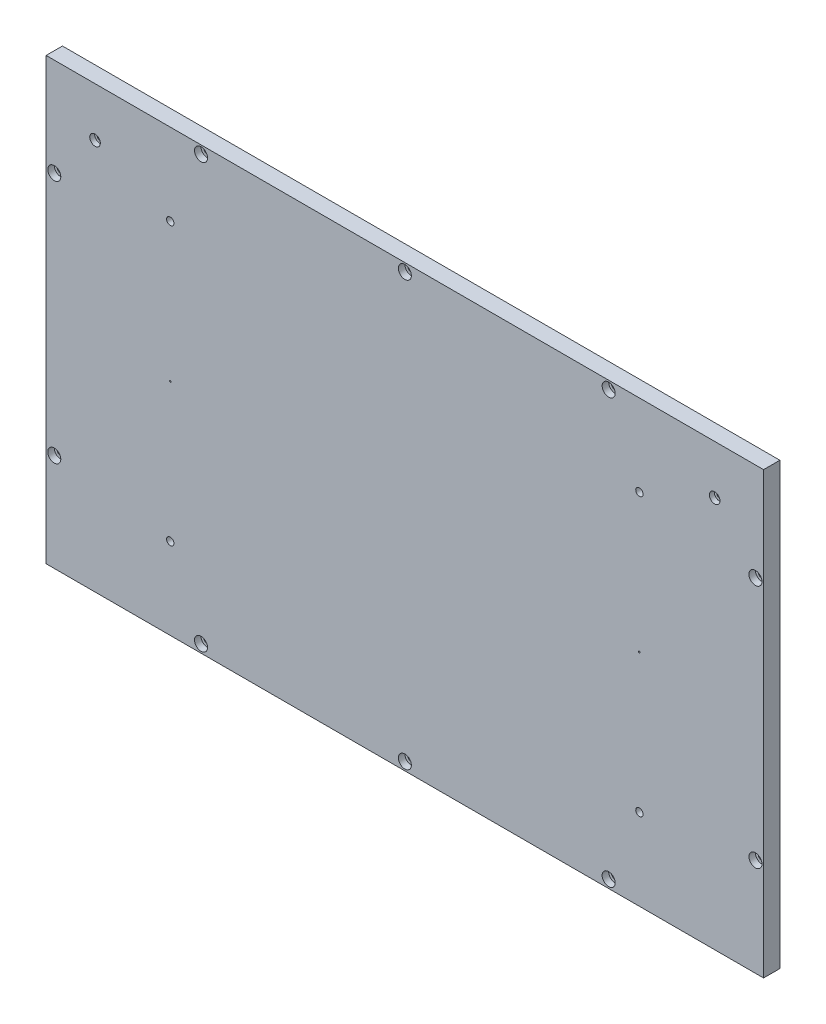
from build123d import *

# Parameters (mm, degrees)
SKETCH1_W                      = 440
SKETCH1_H                      = 270
BOSS_EXTRUDE1_DEPTH            = 10
CBORE_FOR_M4_SHCS4_D           = 4.5
CBORE_FOR_M4_SHCS4_DEPTH       = 11.5
CBORE_FOR_M4_SHCS4_CBORE_D     = 8
CBORE_FOR_M4_SHCS4_CBORE_DEPTH = 4
CBORE_FOR_M4_SHCS4_TIP         = 1.351936393
CBORE_FOR_M3_SHCS1_D           = 3.4
CBORE_FOR_M3_SHCS1_CBORE_D     = 6.5
CBORE_FOR_M3_SHCS1_CBORE_DEPTH = 3


with BuildPart() as part:
    # Sketch1 → Boss-Extrude1 (new body)
    with BuildSketch(Plane.XY):
        with Locations((190, 105)):
            Rectangle(SKETCH1_W, SKETCH1_H)
    extrude(amount=-BOSS_EXTRUDE1_DEPTH)

    # Sketch7 → CBORE for M4 SHCS3 (revolve, cut)
    with BuildSketch(Plane(origin=(46.15, 20, -10), x_dir=(0, 1, 0), z_dir=(1, 0, 0))):
        Polygon((0, 0), (0, 12.851936393), (2.25, 11.5), (2.25, 4), (4, 4), (4, 0), align=None)
    cbore_for_m4_shcs3 = revolve(axis=Axis((46.15, 20, -16.35), (0, 0, 1)), mode=Mode.SUBTRACT)

    # Mirror1: CBORE for M4 SHCS3 across plane
    add(cbore_for_m4_shcs3.mirror(Plane(origin=(0, 105, 0), x_dir=(0, 0, 1), z_dir=(0, -1, 0))), mode=Mode.SUBTRACT)

    # Mirror2: CBORE for M4 SHCS3 across plane
    add(cbore_for_m4_shcs3.mirror(Plane.ZY.offset(-190)), mode=Mode.SUBTRACT)

    # Mirror2 copy 1 sketch → Mirror2 copy 1 (revolve, cut)
    with BuildSketch(Plane(origin=(333.85, 190, -10), x_dir=(0, -1, 0), z_dir=(-1, 0, 0))):
        Polygon((0, 0), (0, 12.851936393), (2.25, 11.5), (2.25, 4), (4, 4), (4, 0), align=None)
    revolve(axis=Axis((333.85, 190, -16.35), (0, 0, 1)), mode=Mode.SUBTRACT)

    # CBORE for M4 SHCS4
    with Locations(Plane.XY):
        with Locations((65, 235), (190, 235), (315, 235), (315, -25), (190, -25), (65, -25), (405, 180), (405, 30), (-25, 30), (-25, 180)):
            CounterBoreHole(CBORE_FOR_M4_SHCS4_D / 2, CBORE_FOR_M4_SHCS4_CBORE_D / 2, CBORE_FOR_M4_SHCS4_CBORE_DEPTH, depth=CBORE_FOR_M4_SHCS4_DEPTH)
            with Locations((0, 0, -(CBORE_FOR_M4_SHCS4_DEPTH + CBORE_FOR_M4_SHCS4_TIP / 2))):  # 118° drill point
                Cone(0, CBORE_FOR_M4_SHCS4_D / 2, CBORE_FOR_M4_SHCS4_TIP, mode=Mode.SUBTRACT)

    # Sketch11 → Ø1.0mm Dowel Hole1 (revolve, cut)
    with BuildSketch(Plane(origin=(46.15, 105, 0), x_dir=(0, -1, 0), z_dir=(1, 0, 0))):
        Polygon((0, 0), (0, 5.30043031), (0.5, 5), (0.5, 0), align=None)
    f_1_0mm_dowel_hole1 = revolve(axis=Axis((46.15, 105, 6.35), (0, 0, -1)), mode=Mode.SUBTRACT)

    # Mirror3: Ø1.0mm Dowel Hole1 across plane
    add(f_1_0mm_dowel_hole1.mirror(Plane.ZY.offset(-190)), mode=Mode.SUBTRACT)

    # CBORE for M3 SHCS1 (through all)
    with Locations(Plane.XY):
        with Locations((0, 210)):
            cbore_for_m3_shcs1 = CounterBoreHole(CBORE_FOR_M3_SHCS1_D / 2, CBORE_FOR_M3_SHCS1_CBORE_D / 2, CBORE_FOR_M3_SHCS1_CBORE_DEPTH)

    # Mirror4: CBORE for M3 SHCS1 across plane
    add(cbore_for_m3_shcs1.mirror(Plane.ZY.offset(-190)), mode=Mode.SUBTRACT)


solid = part.part
